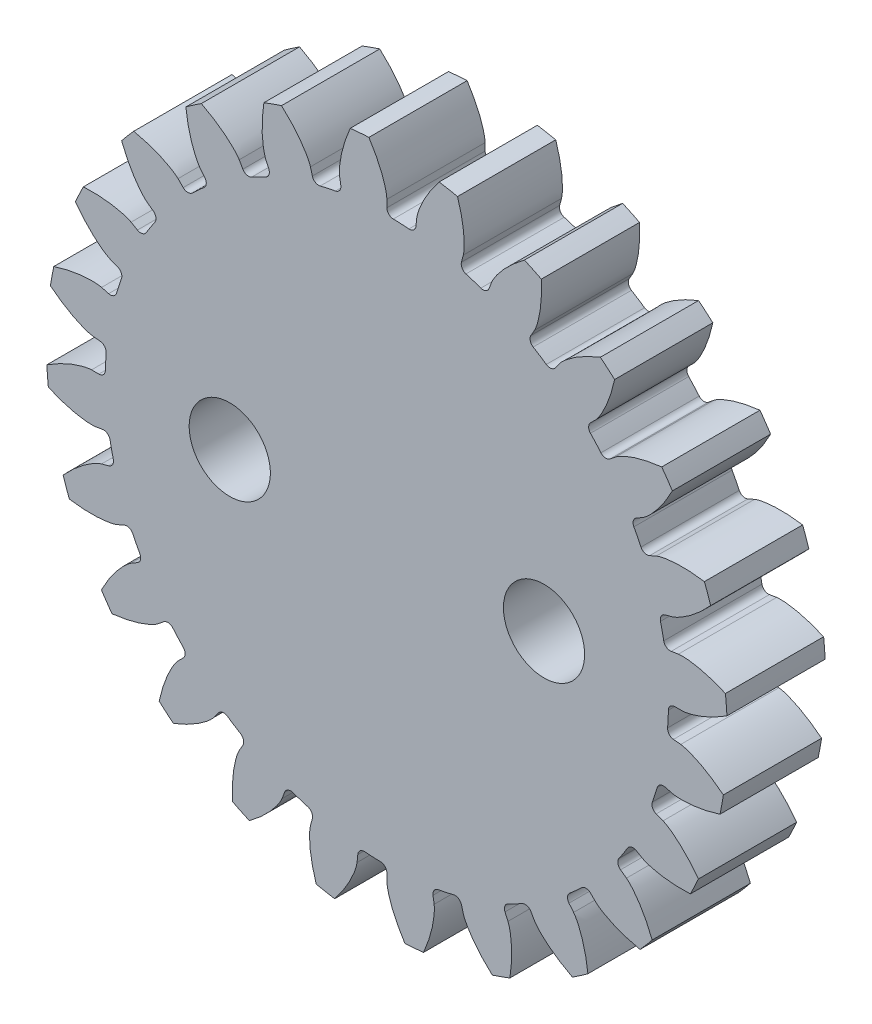
from build123d import *

# Parameters (mm, degrees)
SKETCH_3_R               = 26
EXTRUDE_2_DEPTH          = 7.5
CUT_EXTRUDE_2_DEPTH      = 8.5
PATTERN_CIRCULAR_1_COUNT = 24
MIRROR_1_COPY_1_DEPTH    = 8.5
MIRROR_1_COPY_2_DEPTH    = 8.5
MIRROR_1_COPY_3_DEPTH    = 8.5
MIRROR_1_COPY_4_DEPTH    = 8.5
MIRROR_1_COPY_5_DEPTH    = 8.5
MIRROR_1_COPY_6_DEPTH    = 8.5
MIRROR_1_COPY_7_DEPTH    = 8.5
MIRROR_1_COPY_8_DEPTH    = 8.5
MIRROR_1_COPY_9_DEPTH    = 8.5
MIRROR_1_COPY_10_DEPTH   = 8.5
MIRROR_1_COPY_11_DEPTH   = 8.5
MIRROR_1_COPY_12_DEPTH   = 8.5
MIRROR_1_COPY_13_DEPTH   = 8.5
MIRROR_1_COPY_14_DEPTH   = 8.5
MIRROR_1_COPY_15_DEPTH   = 8.5
MIRROR_1_COPY_16_DEPTH   = 8.5
MIRROR_1_COPY_17_DEPTH   = 8.5
MIRROR_1_COPY_18_DEPTH   = 8.5
MIRROR_1_COPY_19_DEPTH   = 8.5
MIRROR_1_COPY_20_DEPTH   = 8.5
MIRROR_1_COPY_21_DEPTH   = 8.5
MIRROR_1_COPY_22_DEPTH   = 8.5
MIRROR_1_COPY_23_DEPTH   = 8.5
FILLET_5_R               = 0.5
SKETCH_10_R              = 3.1
CUT_EXTRUDE_4_DEPTH      = 8.5000001


with BuildPart() as part:
    # ｽｹｯﾁ3 → ﾎﾞｽ - 押し出し2 (new body)
    with BuildSketch(Plane.XY):
        Circle(SKETCH_3_R)
    extrude(amount=EXTRUDE_2_DEPTH)

    # ｽｹｯﾁ4 → ｶｯﾄ - 押し出し2 (cut, through all)
    with BuildSketch(Plane.XY):
        with BuildLine():
            Line((21.472541613, -1.086258116), (25.966794508, -1.313614466))
            ThreePointArc((25.966794508, -1.313614466), (25.99998299, 0.029741003), (25.963721309, 1.373017029))
            add(Edge.make_bspline(
                [(22.552622899, 0), (22.58737922, 0.001108669), (22.656749084, 0.005403897), (22.850516265, 0.028314483), (23.215577821, 0.099947013), (23.763996392, 0.257632086), (24.493326716, 0.545763948), (25.148201555, 0.876714847), (25.627692166, 1.158881091), (25.900535651, 1.332190349), (25.963721309, 1.373017029)],
                knots=[0, 0, 0, 0, 0, 0.002802036, 0.005604071, 0.015718253, 0.029959921, 0.048733673, 0.068727069, 0.074791923, 0.074791923, 0.074791923, 0.074791923, 0.074791923], degree=4))
            Line((22.552622899, 0), (21.5, 0))
            ThreePointArc((21.5, 0), (21.493134307, -0.543302553), (21.472541613, -1.086258116))
        make_face()
    cut_extrude_2 = extrude(amount=CUT_EXTRUDE_2_DEPTH, mode=Mode.SUBTRACT)

    # 円形ﾊﾟﾀｰﾝ1: ｶｯﾄ - 押し出し2 ×24 about axis
    pattern_circular_1_axis = Axis((0, 0, 7.5), (0, 0, -1))
    for i in range(1, PATTERN_CIRCULAR_1_COUNT):
        add(cut_extrude_2.rotate(pattern_circular_1_axis, i * 360 / PATTERN_CIRCULAR_1_COUNT), mode=Mode.SUBTRACT)

    # ﾐﾗｰ1: ｶｯﾄ - 押し出し2 across plane
    add(cut_extrude_2.mirror(Plane(origin=(21.472541613, -1.086258116, 7.5), x_dir=(0, 0, 1), z_dir=(0.050523633, 0.998722866, 0))), mode=Mode.SUBTRACT)

    # ﾐﾗｰ1 copy 1 sketch → ﾐﾗｰ1 copy 1 (cut, through all)
    with BuildSketch(Plane(origin=(0, 0, 0), x_dir=(0.987114065, 0.160018192, 0), z_dir=(0, 0, 1))):
        with BuildLine():
            Line((21.472541613, 1.086258116), (25.966794508, 1.313614466))
            ThreePointArc((25.966794508, 1.313614466), (25.99998299, -0.029741003), (25.963721309, -1.373017029))
            add(Edge.make_bspline(
                [(22.552622899, 0), (22.58737922, -0.001108669), (22.656749084, -0.005403897), (22.850516265, -0.028314483), (23.215577821, -0.099947013), (23.763996392, -0.257632086), (24.493326716, -0.545763948), (25.148201555, -0.876714847), (25.627692166, -1.158881091), (25.900535651, -1.332190349), (25.963721309, -1.373017029)],
                knots=[0, 0, 0, 0, 0, 0.002802036, 0.005604071, 0.015718253, 0.029959921, 0.048733673, 0.068727069, 0.074791923, 0.074791923, 0.074791923, 0.074791923, 0.074791923], degree=4))
            Line((22.552622899, 0), (21.5, 0))
            ThreePointArc((21.5, 0), (21.493134307, 0.543302553), (21.472541613, 1.086258116))
        make_face()
    extrude(amount=MIRROR_1_COPY_1_DEPTH, mode=Mode.SUBTRACT)

    # ﾐﾗｰ1 copy 2 sketch → ﾐﾗｰ1 copy 2 (cut, through all)
    with BuildSketch(Plane(origin=(0, 0, 0), x_dir=(0.912063214, 0.410049624, 0), z_dir=(0, 0, 1))):
        with BuildLine():
            Line((21.472541613, 1.086258116), (25.966794508, 1.313614466))
            ThreePointArc((25.966794508, 1.313614466), (25.99998299, -0.029741003), (25.963721309, -1.373017029))
            add(Edge.make_bspline(
                [(22.552622899, 0), (22.58737922, -0.001108669), (22.656749084, -0.005403897), (22.850516265, -0.028314483), (23.215577821, -0.099947013), (23.763996392, -0.257632086), (24.493326716, -0.545763948), (25.148201555, -0.876714847), (25.627692166, -1.158881091), (25.900535651, -1.332190349), (25.963721309, -1.373017029)],
                knots=[0, 0, 0, 0, 0, 0.002802036, 0.005604071, 0.015718253, 0.029959921, 0.048733673, 0.068727069, 0.074791923, 0.074791923, 0.074791923, 0.074791923, 0.074791923], degree=4))
            Line((22.552622899, 0), (21.5, 0))
            ThreePointArc((21.5, 0), (21.493134307, 0.543302553), (21.472541613, 1.086258116))
        make_face()
    extrude(amount=MIRROR_1_COPY_2_DEPTH, mode=Mode.SUBTRACT)

    # ﾐﾗｰ1 copy 3 sketch → ﾐﾗｰ1 copy 3 (cut, through all)
    with BuildSketch(Plane(origin=(0, 0, 0), x_dir=(0.774856761, 0.632136852, 0), z_dir=(0, 0, 1))):
        with BuildLine():
            Line((21.472541613, 1.086258116), (25.966794508, 1.313614466))
            ThreePointArc((25.966794508, 1.313614466), (25.99998299, -0.029741003), (25.963721309, -1.373017029))
            add(Edge.make_bspline(
                [(22.552622899, 0), (22.58737922, -0.001108669), (22.656749084, -0.005403897), (22.850516265, -0.028314483), (23.215577821, -0.099947013), (23.763996392, -0.257632086), (24.493326716, -0.545763948), (25.148201555, -0.876714847), (25.627692166, -1.158881091), (25.900535651, -1.332190349), (25.963721309, -1.373017029)],
                knots=[0, 0, 0, 0, 0, 0.002802036, 0.005604071, 0.015718253, 0.029959921, 0.048733673, 0.068727069, 0.074791923, 0.074791923, 0.074791923, 0.074791923, 0.074791923], degree=4))
            Line((22.552622899, 0), (21.5, 0))
            ThreePointArc((21.5, 0), (21.493134307, 0.543302553), (21.472541613, 1.086258116))
        make_face()
    extrude(amount=MIRROR_1_COPY_3_DEPTH, mode=Mode.SUBTRACT)

    # ﾐﾗｰ1 copy 4 sketch → ﾐﾗｰ1 copy 4 (cut, through all)
    with BuildSketch(Plane(origin=(0, 0, 0), x_dir=(0.584845101, 0.811144998, 0), z_dir=(0, 0, 1))):
        with BuildLine():
            Line((21.472541613, 1.086258116), (25.966794508, 1.313614466))
            ThreePointArc((25.966794508, 1.313614466), (25.99998299, -0.029741003), (25.963721309, -1.373017029))
            add(Edge.make_bspline(
                [(22.552622899, 0), (22.58737922, -0.001108669), (22.656749084, -0.005403897), (22.850516265, -0.028314483), (23.215577821, -0.099947013), (23.763996392, -0.257632086), (24.493326716, -0.545763948), (25.148201555, -0.876714847), (25.627692166, -1.158881091), (25.900535651, -1.332190349), (25.963721309, -1.373017029)],
                knots=[0, 0, 0, 0, 0, 0.002802036, 0.005604071, 0.015718253, 0.029959921, 0.048733673, 0.068727069, 0.074791923, 0.074791923, 0.074791923, 0.074791923, 0.074791923], degree=4))
            Line((22.552622899, 0), (21.5, 0))
            ThreePointArc((21.5, 0), (21.493134307, 0.543302553), (21.472541613, 1.086258116))
        make_face()
    extrude(amount=MIRROR_1_COPY_4_DEPTH, mode=Mode.SUBTRACT)

    # ﾐﾗｰ1 copy 5 sketch → ﾐﾗｰ1 copy 5 (cut, through all)
    with BuildSketch(Plane(origin=(0, 0, 0), x_dir=(0.354977214, 0.934874953, 0), z_dir=(0, 0, 1))):
        with BuildLine():
            Line((21.472541613, 1.086258116), (25.966794508, 1.313614466))
            ThreePointArc((25.966794508, 1.313614466), (25.99998299, -0.029741003), (25.963721309, -1.373017029))
            add(Edge.make_bspline(
                [(22.552622899, 0), (22.58737922, -0.001108669), (22.656749084, -0.005403897), (22.850516265, -0.028314483), (23.215577821, -0.099947013), (23.763996392, -0.257632086), (24.493326716, -0.545763948), (25.148201555, -0.876714847), (25.627692166, -1.158881091), (25.900535651, -1.332190349), (25.963721309, -1.373017029)],
                knots=[0, 0, 0, 0, 0, 0.002802036, 0.005604071, 0.015718253, 0.029959921, 0.048733673, 0.068727069, 0.074791923, 0.074791923, 0.074791923, 0.074791923, 0.074791923], degree=4))
            Line((22.552622899, 0), (21.5, 0))
            ThreePointArc((21.5, 0), (21.493134307, 0.543302553), (21.472541613, 1.086258116))
        make_face()
    extrude(amount=MIRROR_1_COPY_5_DEPTH, mode=Mode.SUBTRACT)

    # ﾐﾗｰ1 copy 6 sketch → ﾐﾗｰ1 copy 6 (cut, through all)
    with BuildSketch(Plane(origin=(0, 0, 0), x_dir=(0.100918216, 0.994894725, 0), z_dir=(0, 0, 1))):
        with BuildLine():
            Line((21.472541613, 1.086258116), (25.966794508, 1.313614466))
            ThreePointArc((25.966794508, 1.313614466), (25.99998299, -0.029741003), (25.963721309, -1.373017029))
            add(Edge.make_bspline(
                [(22.552622899, 0), (22.58737922, -0.001108669), (22.656749084, -0.005403897), (22.850516265, -0.028314483), (23.215577821, -0.099947013), (23.763996392, -0.257632086), (24.493326716, -0.545763948), (25.148201555, -0.876714847), (25.627692166, -1.158881091), (25.900535651, -1.332190349), (25.963721309, -1.373017029)],
                knots=[0, 0, 0, 0, 0, 0.002802036, 0.005604071, 0.015718253, 0.029959921, 0.048733673, 0.068727069, 0.074791923, 0.074791923, 0.074791923, 0.074791923, 0.074791923], degree=4))
            Line((22.552622899, 0), (21.5, 0))
            ThreePointArc((21.5, 0), (21.493134307, 0.543302553), (21.472541613, 1.086258116))
        make_face()
    extrude(amount=MIRROR_1_COPY_6_DEPTH, mode=Mode.SUBTRACT)

    # ﾐﾗｰ1 copy 7 sketch → ﾐﾗｰ1 copy 7 (cut, through all)
    with BuildSketch(Plane(origin=(0, 0, 0), x_dir=(-0.160018192, 0.987114065, 0), z_dir=(0, 0, 1))):
        with BuildLine():
            Line((21.472541613, 1.086258116), (25.966794508, 1.313614466))
            ThreePointArc((25.966794508, 1.313614466), (25.99998299, -0.029741003), (25.963721309, -1.373017029))
            add(Edge.make_bspline(
                [(22.552622899, 0), (22.58737922, -0.001108669), (22.656749084, -0.005403897), (22.850516265, -0.028314483), (23.215577821, -0.099947013), (23.763996392, -0.257632086), (24.493326716, -0.545763948), (25.148201555, -0.876714847), (25.627692166, -1.158881091), (25.900535651, -1.332190349), (25.963721309, -1.373017029)],
                knots=[0, 0, 0, 0, 0, 0.002802036, 0.005604071, 0.015718253, 0.029959921, 0.048733673, 0.068727069, 0.074791923, 0.074791923, 0.074791923, 0.074791923, 0.074791923], degree=4))
            Line((22.552622899, 0), (21.5, 0))
            ThreePointArc((21.5, 0), (21.493134307, 0.543302553), (21.472541613, 1.086258116))
        make_face()
    extrude(amount=MIRROR_1_COPY_7_DEPTH, mode=Mode.SUBTRACT)

    # ﾐﾗｰ1 copy 8 sketch → ﾐﾗｰ1 copy 8 (cut, through all)
    with BuildSketch(Plane(origin=(0, 0, 0), x_dir=(-0.410049624, 0.912063214, 0), z_dir=(0, 0, 1))):
        with BuildLine():
            Line((21.472541613, 1.086258116), (25.966794508, 1.313614466))
            ThreePointArc((25.966794508, 1.313614466), (25.99998299, -0.029741003), (25.963721309, -1.373017029))
            add(Edge.make_bspline(
                [(22.552622899, 0), (22.58737922, -0.001108669), (22.656749084, -0.005403897), (22.850516265, -0.028314483), (23.215577821, -0.099947013), (23.763996392, -0.257632086), (24.493326716, -0.545763948), (25.148201555, -0.876714847), (25.627692166, -1.158881091), (25.900535651, -1.332190349), (25.963721309, -1.373017029)],
                knots=[0, 0, 0, 0, 0, 0.002802036, 0.005604071, 0.015718253, 0.029959921, 0.048733673, 0.068727069, 0.074791923, 0.074791923, 0.074791923, 0.074791923, 0.074791923], degree=4))
            Line((22.552622899, 0), (21.5, 0))
            ThreePointArc((21.5, 0), (21.493134307, 0.543302553), (21.472541613, 1.086258116))
        make_face()
    extrude(amount=MIRROR_1_COPY_8_DEPTH, mode=Mode.SUBTRACT)

    # ﾐﾗｰ1 copy 9 sketch → ﾐﾗｰ1 copy 9 (cut, through all)
    with BuildSketch(Plane(origin=(0, 0, 0), x_dir=(-0.632136852, 0.774856761, 0), z_dir=(0, 0, 1))):
        with BuildLine():
            Line((21.472541613, 1.086258116), (25.966794508, 1.313614466))
            ThreePointArc((25.966794508, 1.313614466), (25.99998299, -0.029741003), (25.963721309, -1.373017029))
            add(Edge.make_bspline(
                [(22.552622899, 0), (22.58737922, -0.001108669), (22.656749084, -0.005403897), (22.850516265, -0.028314483), (23.215577821, -0.099947013), (23.763996392, -0.257632086), (24.493326716, -0.545763948), (25.148201555, -0.876714847), (25.627692166, -1.158881091), (25.900535651, -1.332190349), (25.963721309, -1.373017029)],
                knots=[0, 0, 0, 0, 0, 0.002802036, 0.005604071, 0.015718253, 0.029959921, 0.048733673, 0.068727069, 0.074791923, 0.074791923, 0.074791923, 0.074791923, 0.074791923], degree=4))
            Line((22.552622899, 0), (21.5, 0))
            ThreePointArc((21.5, 0), (21.493134307, 0.543302553), (21.472541613, 1.086258116))
        make_face()
    extrude(amount=MIRROR_1_COPY_9_DEPTH, mode=Mode.SUBTRACT)

    # ﾐﾗｰ1 copy 10 sketch → ﾐﾗｰ1 copy 10 (cut, through all)
    with BuildSketch(Plane(origin=(0, 0, 0), x_dir=(-0.811144998, 0.584845101, 0), z_dir=(0, 0, 1))):
        with BuildLine():
            Line((21.472541613, 1.086258116), (25.966794508, 1.313614466))
            ThreePointArc((25.966794508, 1.313614466), (25.99998299, -0.029741003), (25.963721309, -1.373017029))
            add(Edge.make_bspline(
                [(22.552622899, 0), (22.58737922, -0.001108669), (22.656749084, -0.005403897), (22.850516265, -0.028314483), (23.215577821, -0.099947013), (23.763996392, -0.257632086), (24.493326716, -0.545763948), (25.148201555, -0.876714847), (25.627692166, -1.158881091), (25.900535651, -1.332190349), (25.963721309, -1.373017029)],
                knots=[0, 0, 0, 0, 0, 0.002802036, 0.005604071, 0.015718253, 0.029959921, 0.048733673, 0.068727069, 0.074791923, 0.074791923, 0.074791923, 0.074791923, 0.074791923], degree=4))
            Line((22.552622899, 0), (21.5, 0))
            ThreePointArc((21.5, 0), (21.493134307, 0.543302553), (21.472541613, 1.086258116))
        make_face()
    extrude(amount=MIRROR_1_COPY_10_DEPTH, mode=Mode.SUBTRACT)

    # ﾐﾗｰ1 copy 11 sketch → ﾐﾗｰ1 copy 11 (cut, through all)
    with BuildSketch(Plane(origin=(0, 0, 0), x_dir=(-0.934874953, 0.354977214, 0), z_dir=(0, 0, 1))):
        with BuildLine():
            Line((21.472541613, 1.086258116), (25.966794508, 1.313614466))
            ThreePointArc((25.966794508, 1.313614466), (25.99998299, -0.029741003), (25.963721309, -1.373017029))
            add(Edge.make_bspline(
                [(22.552622899, 0), (22.58737922, -0.001108669), (22.656749084, -0.005403897), (22.850516265, -0.028314483), (23.215577821, -0.099947013), (23.763996392, -0.257632086), (24.493326716, -0.545763948), (25.148201555, -0.876714847), (25.627692166, -1.158881091), (25.900535651, -1.332190349), (25.963721309, -1.373017029)],
                knots=[0, 0, 0, 0, 0, 0.002802036, 0.005604071, 0.015718253, 0.029959921, 0.048733673, 0.068727069, 0.074791923, 0.074791923, 0.074791923, 0.074791923, 0.074791923], degree=4))
            Line((22.552622899, 0), (21.5, 0))
            ThreePointArc((21.5, 0), (21.493134307, 0.543302553), (21.472541613, 1.086258116))
        make_face()
    extrude(amount=MIRROR_1_COPY_11_DEPTH, mode=Mode.SUBTRACT)

    # ﾐﾗｰ1 copy 12 sketch → ﾐﾗｰ1 copy 12 (cut, through all)
    with BuildSketch(Plane(origin=(0, 0, 0), x_dir=(-0.994894725, 0.100918216, 0), z_dir=(0, 0, 1))):
        with BuildLine():
            Line((21.472541613, 1.086258116), (25.966794508, 1.313614466))
            ThreePointArc((25.966794508, 1.313614466), (25.99998299, -0.029741003), (25.963721309, -1.373017029))
            add(Edge.make_bspline(
                [(22.552622899, 0), (22.58737922, -0.001108669), (22.656749084, -0.005403897), (22.850516265, -0.028314483), (23.215577821, -0.099947013), (23.763996392, -0.257632086), (24.493326716, -0.545763948), (25.148201555, -0.876714847), (25.627692166, -1.158881091), (25.900535651, -1.332190349), (25.963721309, -1.373017029)],
                knots=[0, 0, 0, 0, 0, 0.002802036, 0.005604071, 0.015718253, 0.029959921, 0.048733673, 0.068727069, 0.074791923, 0.074791923, 0.074791923, 0.074791923, 0.074791923], degree=4))
            Line((22.552622899, 0), (21.5, 0))
            ThreePointArc((21.5, 0), (21.493134307, 0.543302553), (21.472541613, 1.086258116))
        make_face()
    extrude(amount=MIRROR_1_COPY_12_DEPTH, mode=Mode.SUBTRACT)

    # ﾐﾗｰ1 copy 13 sketch → ﾐﾗｰ1 copy 13 (cut, through all)
    with BuildSketch(Plane(origin=(0, 0, 0), x_dir=(-0.987114065, -0.160018192, 0), z_dir=(0, 0, 1))):
        with BuildLine():
            Line((21.472541613, 1.086258116), (25.966794508, 1.313614466))
            ThreePointArc((25.966794508, 1.313614466), (25.99998299, -0.029741003), (25.963721309, -1.373017029))
            add(Edge.make_bspline(
                [(22.552622899, 0), (22.58737922, -0.001108669), (22.656749084, -0.005403897), (22.850516265, -0.028314483), (23.215577821, -0.099947013), (23.763996392, -0.257632086), (24.493326716, -0.545763948), (25.148201555, -0.876714847), (25.627692166, -1.158881091), (25.900535651, -1.332190349), (25.963721309, -1.373017029)],
                knots=[0, 0, 0, 0, 0, 0.002802036, 0.005604071, 0.015718253, 0.029959921, 0.048733673, 0.068727069, 0.074791923, 0.074791923, 0.074791923, 0.074791923, 0.074791923], degree=4))
            Line((22.552622899, 0), (21.5, 0))
            ThreePointArc((21.5, 0), (21.493134307, 0.543302553), (21.472541613, 1.086258116))
        make_face()
    extrude(amount=MIRROR_1_COPY_13_DEPTH, mode=Mode.SUBTRACT)

    # ﾐﾗｰ1 copy 14 sketch → ﾐﾗｰ1 copy 14 (cut, through all)
    with BuildSketch(Plane(origin=(0, 0, 0), x_dir=(-0.912063214, -0.410049624, 0), z_dir=(0, 0, 1))):
        with BuildLine():
            Line((21.472541613, 1.086258116), (25.966794508, 1.313614466))
            ThreePointArc((25.966794508, 1.313614466), (25.99998299, -0.029741003), (25.963721309, -1.373017029))
            add(Edge.make_bspline(
                [(22.552622899, 0), (22.58737922, -0.001108669), (22.656749084, -0.005403897), (22.850516265, -0.028314483), (23.215577821, -0.099947013), (23.763996392, -0.257632086), (24.493326716, -0.545763948), (25.148201555, -0.876714847), (25.627692166, -1.158881091), (25.900535651, -1.332190349), (25.963721309, -1.373017029)],
                knots=[0, 0, 0, 0, 0, 0.002802036, 0.005604071, 0.015718253, 0.029959921, 0.048733673, 0.068727069, 0.074791923, 0.074791923, 0.074791923, 0.074791923, 0.074791923], degree=4))
            Line((22.552622899, 0), (21.5, 0))
            ThreePointArc((21.5, 0), (21.493134307, 0.543302553), (21.472541613, 1.086258116))
        make_face()
    extrude(amount=MIRROR_1_COPY_14_DEPTH, mode=Mode.SUBTRACT)

    # ﾐﾗｰ1 copy 15 sketch → ﾐﾗｰ1 copy 15 (cut, through all)
    with BuildSketch(Plane(origin=(0, 0, 0), x_dir=(-0.774856761, -0.632136852, 0), z_dir=(0, 0, 1))):
        with BuildLine():
            Line((21.472541613, 1.086258116), (25.966794508, 1.313614466))
            ThreePointArc((25.966794508, 1.313614466), (25.99998299, -0.029741003), (25.963721309, -1.373017029))
            add(Edge.make_bspline(
                [(22.552622899, 0), (22.58737922, -0.001108669), (22.656749084, -0.005403897), (22.850516265, -0.028314483), (23.215577821, -0.099947013), (23.763996392, -0.257632086), (24.493326716, -0.545763948), (25.148201555, -0.876714847), (25.627692166, -1.158881091), (25.900535651, -1.332190349), (25.963721309, -1.373017029)],
                knots=[0, 0, 0, 0, 0, 0.002802036, 0.005604071, 0.015718253, 0.029959921, 0.048733673, 0.068727069, 0.074791923, 0.074791923, 0.074791923, 0.074791923, 0.074791923], degree=4))
            Line((22.552622899, 0), (21.5, 0))
            ThreePointArc((21.5, 0), (21.493134307, 0.543302553), (21.472541613, 1.086258116))
        make_face()
    extrude(amount=MIRROR_1_COPY_15_DEPTH, mode=Mode.SUBTRACT)

    # ﾐﾗｰ1 copy 16 sketch → ﾐﾗｰ1 copy 16 (cut, through all)
    with BuildSketch(Plane(origin=(0, 0, 0), x_dir=(-0.584845101, -0.811144998, 0), z_dir=(0, 0, 1))):
        with BuildLine():
            Line((21.472541613, 1.086258116), (25.966794508, 1.313614466))
            ThreePointArc((25.966794508, 1.313614466), (25.99998299, -0.029741003), (25.963721309, -1.373017029))
            add(Edge.make_bspline(
                [(22.552622899, 0), (22.58737922, -0.001108669), (22.656749084, -0.005403897), (22.850516265, -0.028314483), (23.215577821, -0.099947013), (23.763996392, -0.257632086), (24.493326716, -0.545763948), (25.148201555, -0.876714847), (25.627692166, -1.158881091), (25.900535651, -1.332190349), (25.963721309, -1.373017029)],
                knots=[0, 0, 0, 0, 0, 0.002802036, 0.005604071, 0.015718253, 0.029959921, 0.048733673, 0.068727069, 0.074791923, 0.074791923, 0.074791923, 0.074791923, 0.074791923], degree=4))
            Line((22.552622899, 0), (21.5, 0))
            ThreePointArc((21.5, 0), (21.493134307, 0.543302553), (21.472541613, 1.086258116))
        make_face()
    extrude(amount=MIRROR_1_COPY_16_DEPTH, mode=Mode.SUBTRACT)

    # ﾐﾗｰ1 copy 17 sketch → ﾐﾗｰ1 copy 17 (cut, through all)
    with BuildSketch(Plane(origin=(0, 0, 0), x_dir=(-0.354977214, -0.934874953, 0), z_dir=(0, 0, 1))):
        with BuildLine():
            Line((21.472541613, 1.086258116), (25.966794508, 1.313614466))
            ThreePointArc((25.966794508, 1.313614466), (25.99998299, -0.029741003), (25.963721309, -1.373017029))
            add(Edge.make_bspline(
                [(22.552622899, 0), (22.58737922, -0.001108669), (22.656749084, -0.005403897), (22.850516265, -0.028314483), (23.215577821, -0.099947013), (23.763996392, -0.257632086), (24.493326716, -0.545763948), (25.148201555, -0.876714847), (25.627692166, -1.158881091), (25.900535651, -1.332190349), (25.963721309, -1.373017029)],
                knots=[0, 0, 0, 0, 0, 0.002802036, 0.005604071, 0.015718253, 0.029959921, 0.048733673, 0.068727069, 0.074791923, 0.074791923, 0.074791923, 0.074791923, 0.074791923], degree=4))
            Line((22.552622899, 0), (21.5, 0))
            ThreePointArc((21.5, 0), (21.493134307, 0.543302553), (21.472541613, 1.086258116))
        make_face()
    extrude(amount=MIRROR_1_COPY_17_DEPTH, mode=Mode.SUBTRACT)

    # ﾐﾗｰ1 copy 18 sketch → ﾐﾗｰ1 copy 18 (cut, through all)
    with BuildSketch(Plane(origin=(0, 0, 0), x_dir=(-0.100918216, -0.994894725, 0), z_dir=(0, 0, 1))):
        with BuildLine():
            Line((21.472541613, 1.086258116), (25.966794508, 1.313614466))
            ThreePointArc((25.966794508, 1.313614466), (25.99998299, -0.029741003), (25.963721309, -1.373017029))
            add(Edge.make_bspline(
                [(22.552622899, 0), (22.58737922, -0.001108669), (22.656749084, -0.005403897), (22.850516265, -0.028314483), (23.215577821, -0.099947013), (23.763996392, -0.257632086), (24.493326716, -0.545763948), (25.148201555, -0.876714847), (25.627692166, -1.158881091), (25.900535651, -1.332190349), (25.963721309, -1.373017029)],
                knots=[0, 0, 0, 0, 0, 0.002802036, 0.005604071, 0.015718253, 0.029959921, 0.048733673, 0.068727069, 0.074791923, 0.074791923, 0.074791923, 0.074791923, 0.074791923], degree=4))
            Line((22.552622899, 0), (21.5, 0))
            ThreePointArc((21.5, 0), (21.493134307, 0.543302553), (21.472541613, 1.086258116))
        make_face()
    extrude(amount=MIRROR_1_COPY_18_DEPTH, mode=Mode.SUBTRACT)

    # ﾐﾗｰ1 copy 19 sketch → ﾐﾗｰ1 copy 19 (cut, through all)
    with BuildSketch(Plane(origin=(0, 0, 0), x_dir=(0.160018192, -0.987114065, 0), z_dir=(0, 0, 1))):
        with BuildLine():
            Line((21.472541613, 1.086258116), (25.966794508, 1.313614466))
            ThreePointArc((25.966794508, 1.313614466), (25.99998299, -0.029741003), (25.963721309, -1.373017029))
            add(Edge.make_bspline(
                [(22.552622899, 0), (22.58737922, -0.001108669), (22.656749084, -0.005403897), (22.850516265, -0.028314483), (23.215577821, -0.099947013), (23.763996392, -0.257632086), (24.493326716, -0.545763948), (25.148201555, -0.876714847), (25.627692166, -1.158881091), (25.900535651, -1.332190349), (25.963721309, -1.373017029)],
                knots=[0, 0, 0, 0, 0, 0.002802036, 0.005604071, 0.015718253, 0.029959921, 0.048733673, 0.068727069, 0.074791923, 0.074791923, 0.074791923, 0.074791923, 0.074791923], degree=4))
            Line((22.552622899, 0), (21.5, 0))
            ThreePointArc((21.5, 0), (21.493134307, 0.543302553), (21.472541613, 1.086258116))
        make_face()
    extrude(amount=MIRROR_1_COPY_19_DEPTH, mode=Mode.SUBTRACT)

    # ﾐﾗｰ1 copy 20 sketch → ﾐﾗｰ1 copy 20 (cut, through all)
    with BuildSketch(Plane(origin=(0, 0, 0), x_dir=(0.410049624, -0.912063214, 0), z_dir=(0, 0, 1))):
        with BuildLine():
            Line((21.472541613, 1.086258116), (25.966794508, 1.313614466))
            ThreePointArc((25.966794508, 1.313614466), (25.99998299, -0.029741003), (25.963721309, -1.373017029))
            add(Edge.make_bspline(
                [(22.552622899, 0), (22.58737922, -0.001108669), (22.656749084, -0.005403897), (22.850516265, -0.028314483), (23.215577821, -0.099947013), (23.763996392, -0.257632086), (24.493326716, -0.545763948), (25.148201555, -0.876714847), (25.627692166, -1.158881091), (25.900535651, -1.332190349), (25.963721309, -1.373017029)],
                knots=[0, 0, 0, 0, 0, 0.002802036, 0.005604071, 0.015718253, 0.029959921, 0.048733673, 0.068727069, 0.074791923, 0.074791923, 0.074791923, 0.074791923, 0.074791923], degree=4))
            Line((22.552622899, 0), (21.5, 0))
            ThreePointArc((21.5, 0), (21.493134307, 0.543302553), (21.472541613, 1.086258116))
        make_face()
    extrude(amount=MIRROR_1_COPY_20_DEPTH, mode=Mode.SUBTRACT)

    # ﾐﾗｰ1 copy 21 sketch → ﾐﾗｰ1 copy 21 (cut, through all)
    with BuildSketch(Plane(origin=(0, 0, 0), x_dir=(0.632136852, -0.774856761, 0), z_dir=(0, 0, 1))):
        with BuildLine():
            Line((21.472541613, 1.086258116), (25.966794508, 1.313614466))
            ThreePointArc((25.966794508, 1.313614466), (25.99998299, -0.029741003), (25.963721309, -1.373017029))
            add(Edge.make_bspline(
                [(22.552622899, 0), (22.58737922, -0.001108669), (22.656749084, -0.005403897), (22.850516265, -0.028314483), (23.215577821, -0.099947013), (23.763996392, -0.257632086), (24.493326716, -0.545763948), (25.148201555, -0.876714847), (25.627692166, -1.158881091), (25.900535651, -1.332190349), (25.963721309, -1.373017029)],
                knots=[0, 0, 0, 0, 0, 0.002802036, 0.005604071, 0.015718253, 0.029959921, 0.048733673, 0.068727069, 0.074791923, 0.074791923, 0.074791923, 0.074791923, 0.074791923], degree=4))
            Line((22.552622899, 0), (21.5, 0))
            ThreePointArc((21.5, 0), (21.493134307, 0.543302553), (21.472541613, 1.086258116))
        make_face()
    extrude(amount=MIRROR_1_COPY_21_DEPTH, mode=Mode.SUBTRACT)

    # ﾐﾗｰ1 copy 22 sketch → ﾐﾗｰ1 copy 22 (cut, through all)
    with BuildSketch(Plane(origin=(0, 0, 0), x_dir=(0.811144998, -0.584845101, 0), z_dir=(0, 0, 1))):
        with BuildLine():
            Line((21.472541613, 1.086258116), (25.966794508, 1.313614466))
            ThreePointArc((25.966794508, 1.313614466), (25.99998299, -0.029741003), (25.963721309, -1.373017029))
            add(Edge.make_bspline(
                [(22.552622899, 0), (22.58737922, -0.001108669), (22.656749084, -0.005403897), (22.850516265, -0.028314483), (23.215577821, -0.099947013), (23.763996392, -0.257632086), (24.493326716, -0.545763948), (25.148201555, -0.876714847), (25.627692166, -1.158881091), (25.900535651, -1.332190349), (25.963721309, -1.373017029)],
                knots=[0, 0, 0, 0, 0, 0.002802036, 0.005604071, 0.015718253, 0.029959921, 0.048733673, 0.068727069, 0.074791923, 0.074791923, 0.074791923, 0.074791923, 0.074791923], degree=4))
            Line((22.552622899, 0), (21.5, 0))
            ThreePointArc((21.5, 0), (21.493134307, 0.543302553), (21.472541613, 1.086258116))
        make_face()
    extrude(amount=MIRROR_1_COPY_22_DEPTH, mode=Mode.SUBTRACT)

    # ﾐﾗｰ1 copy 23 sketch → ﾐﾗｰ1 copy 23 (cut, through all)
    with BuildSketch(Plane(origin=(0, 0, 0), x_dir=(0.934874953, -0.354977214, 0), z_dir=(0, 0, 1))):
        with BuildLine():
            Line((21.472541613, 1.086258116), (25.966794508, 1.313614466))
            ThreePointArc((25.966794508, 1.313614466), (25.99998299, -0.029741003), (25.963721309, -1.373017029))
            add(Edge.make_bspline(
                [(22.552622899, 0), (22.58737922, -0.001108669), (22.656749084, -0.005403897), (22.850516265, -0.028314483), (23.215577821, -0.099947013), (23.763996392, -0.257632086), (24.493326716, -0.545763948), (25.148201555, -0.876714847), (25.627692166, -1.158881091), (25.900535651, -1.332190349), (25.963721309, -1.373017029)],
                knots=[0, 0, 0, 0, 0, 0.002802036, 0.005604071, 0.015718253, 0.029959921, 0.048733673, 0.068727069, 0.074791923, 0.074791923, 0.074791923, 0.074791923, 0.074791923], degree=4))
            Line((22.552622899, 0), (21.5, 0))
            ThreePointArc((21.5, 0), (21.493134307, 0.543302553), (21.472541613, 1.086258116))
        make_face()
    extrude(amount=MIRROR_1_COPY_23_DEPTH, mode=Mode.SUBTRACT)

    # ﾌｨﾚｯﾄ5
    fillet_5_edges = [part.edges().sort_by_distance(p)[0] for p in [
        (21.5, 0, 3.75),
        (18.619546181, -10.75, 3.75),
        (15.202795796, -15.202795796, 3.75),
        (10.75, -18.619546181, 3.75),
        (5.56460947, -20.767405265, 3.75),
        (0, -21.5, 3.75),
        (-5.56460947, -20.767405265, 3.75),
        (-10.75, -18.619546181, 3.75),
        (-15.202795796, -15.202795796, 3.75),
        (-18.619546181, -10.75, 3.75),
        (-20.767405265, -5.56460947, 3.75),
        (-21.5, 0, 3.75),
        (-20.767405265, 5.56460947, 3.75),
        (-18.619546181, 10.75, 3.75),
        (-15.202795796, 15.202795796, 3.75),
        (-10.75, 18.619546181, 3.75),
        (-5.56460947, 20.767405265, 3.75),
        (0, 21.5, 3.75),
        (5.56460947, 20.767405265, 3.75),
        (10.75, 18.619546181, 3.75),
        (15.202795796, 15.202795796, 3.75),
        (20.767405265, -5.56460947, 3.75),
        (18.619546181, 10.75, 3.75),
        (20.767405265, 5.56460947, 3.75),
        (21.390236586, -2.169741638, 3.75),
        (20.09981149, -7.632010092, 3.75),
        (17.439617458, -12.574169671, 3.75),
        (13.590942316, -16.659420367, 3.75),
        (8.816066915, -19.609359096, 3.75),
        (3.440391123, -21.222952408, 3.75),
        (-2.169741638, -21.390236586, 3.75),
        (-7.632010092, -20.09981149, 3.75),
        (-12.574169671, -17.439617458, 3.75),
        (-16.659420367, -13.590942316, 3.75),
        (-19.609359096, -8.816066915, 3.75),
        (-21.222952408, -3.440391123, 3.75),
        (-21.390236586, 2.169741638, 3.75),
        (-20.09981149, 7.632010092, 3.75),
        (-17.439617458, 12.574169671, 3.75),
        (-13.590942316, 16.659420367, 3.75),
        (-8.816066915, 19.609359096, 3.75),
        (-3.440391123, 21.222952408, 3.75),
        (2.169741638, 21.390236586, 3.75),
        (7.632010092, 20.09981149, 3.75),
        (12.574169671, 17.439617458, 3.75),
        (16.659420367, 13.590942316, 3.75),
        (19.609359096, 8.816066915, 3.75),
        (21.222952408, 3.440391123, 3.75),
    ]]
    fillet(fillet_5_edges, radius=FILLET_5_R)

    # ｽｹｯﾁ10 → ｶｯﾄ - 押し出し4 (cut, through all)
    with BuildSketch(Plane(origin=(0, 0, 0), x_dir=(-1, 0, 0), z_dir=(0, 0, -1))):
        with Locations((-12, 0)):
            Circle(SKETCH_10_R)
        with Locations((12, 0)):
            Circle(SKETCH_10_R)
    extrude(amount=-CUT_EXTRUDE_4_DEPTH, mode=Mode.SUBTRACT)


solid = part.part
